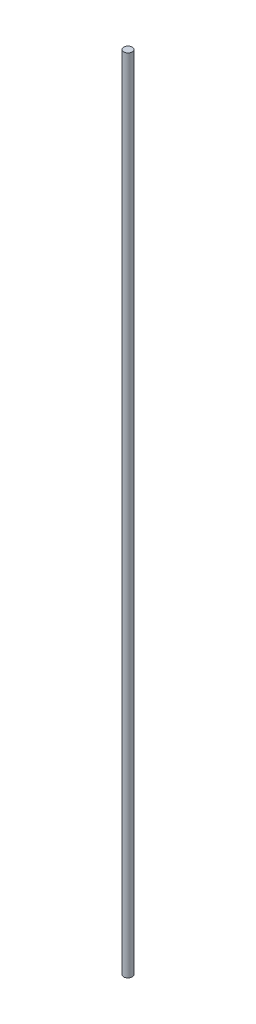
from build123d import *

# Parameters (mm, degrees)
SKETCH_1_R        = 4
EXTRUDE_264_DEPTH = 750


with BuildPart() as part:
    # 草图1 → Extrude 264 (new body)
    with BuildSketch(Plane(origin=(0, 0, 0), x_dir=(1, 0, 0), z_dir=(0, 1, 0))):
        Circle(SKETCH_1_R)
    extrude(amount=EXTRUDE_264_DEPTH)


solid = part.part
